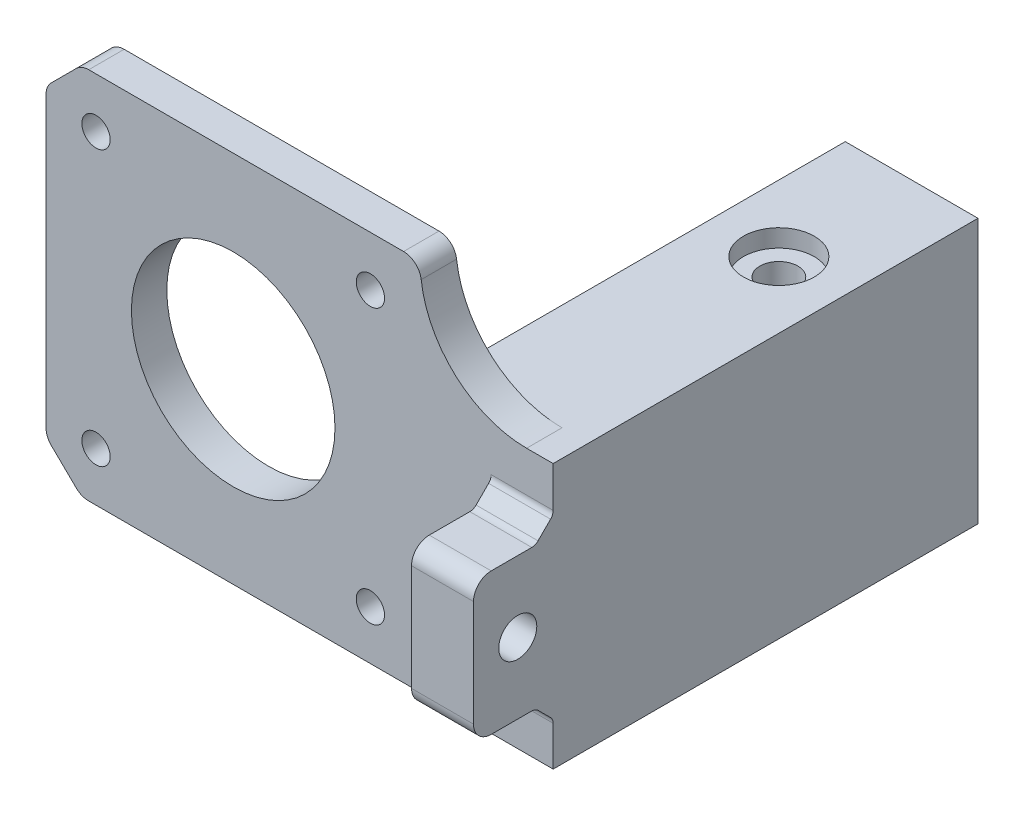
from build123d import *

# Parameters (mm, degrees)
CROQUIS1_R              = 1.6
CROQUIS1_R_2            = 11.5
SALIENTE_EXTRUIR1_DEPTH = 4
CROQUIS2_W              = 9
CROQUIS2_H              = 16
CROQUIS2_R              = 2.15
SALIENTE_EXTRUIR2_DEPTH = 7
CROQUIS3_W              = 15
CROQUIS3_H              = 42.2
SALIENTE_EXTRUIR3_DEPTH = 44
CORTAR_EXTRUIR1_START   = -12.3
CROQUIS4_W              = 15
CROQUIS4_H              = 48
CORTAR_EXTRUIR1_DEPTH   = 12.3
REDONDEO1_R             = 12
REDONDEO2_R             = 2
REDONDEO3_R             = 2
CHAFL_N1_SIZE           = 2
CHAFL_N2_SIZE           = 2
REDONDEO4_R             = 2
REDONDEO5_R             = 1
CROQUIS5_R              = 2.15
CORTAR_EXTRUIR2_DEPTH   = 30.9000001
CROQUIS5_3_R            = 4
CROQUIS5_3_R_2          = 2.15
CORTAR_EXTRUIR3_DEPTH   = 2


with BuildPart() as part:
    # Croquis1 → Saliente-Extruir1 (new body)
    with BuildSketch(Plane.XY):
        Polygon((21.15, 21.15), (17.15, 21.15), (-17.15, 21.15), (-21.15, 17.15), (-21.15, -17.15), (-17.15, -21.05), (17.15, -21.05), (36.15, -21.05), (36.15, 21.15), align=None)
        with Locations((-15.5, 15.5)):
            Circle(CROQUIS1_R, mode=Mode.SUBTRACT)
        with Locations((-15.5, -15.5)):
            Circle(CROQUIS1_R, mode=Mode.SUBTRACT)
        with Locations((15.5, 15.5)):
            Circle(CROQUIS1_R, mode=Mode.SUBTRACT)
        with Locations((15.5, -15.5)):
            Circle(CROQUIS1_R, mode=Mode.SUBTRACT)
        Circle(CROQUIS1_R_2, mode=Mode.SUBTRACT)
    extrude(amount=SALIENTE_EXTRUIR1_DEPTH)

    # Croquis2 → Saliente-Extruir2 (add)
    with BuildSketch(Plane(origin=(36.15, 0, 0), x_dir=(0, 0, -1), z_dir=(1, 0, 0))):
        with Locations((-8.5, -6.15)):
            Rectangle(CROQUIS2_W, CROQUIS2_H)
        with Locations((-8, -6.15)):
            Circle(CROQUIS2_R, mode=Mode.SUBTRACT)
    extrude(amount=-SALIENTE_EXTRUIR2_DEPTH)

    # Croquis3 → Saliente-Extruir3 (add)
    with BuildSketch(Plane(origin=(0, 0, 0), x_dir=(-1, 0, 0), z_dir=(0, 0, -1))):
        with Locations((-28.65, 0.05)):
            Rectangle(CROQUIS3_W, CROQUIS3_H)
    extrude(amount=SALIENTE_EXTRUIR3_DEPTH)

    # Croquis4 → Cortar-Extruir1 (cut)
    with BuildSketch(Plane(origin=(0, 21.15, 0), x_dir=(1, 0, 0), z_dir=(0, 1, 0)).offset(CORTAR_EXTRUIR1_START)):
        with Locations((28.65, 20)):
            Rectangle(CROQUIS4_W, CROQUIS4_H)
    extrude(amount=CORTAR_EXTRUIR1_DEPTH, mode=Mode.SUBTRACT)

    # Redondeo1
    redondeo1_edges = [part.edges().sort_by_distance(p)[0] for p in [
        (21.15, 8.85, 2),
    ]]
    fillet(redondeo1_edges, radius=REDONDEO1_R)

    # Redondeo2
    redondeo2_edges = [part.edges().sort_by_distance(p)[0] for p in [
        (21.15, 21.15, 2),
    ]]
    fillet(redondeo2_edges, radius=REDONDEO2_R)

    # Redondeo3
    redondeo3_edges = [part.edges().sort_by_distance(p)[0] for p in [
        (-17.15, -21.05, 2),
        (-21.15, -17.15, 2),
        (-21.15, 17.15, 2),
        (-17.15, 21.15, 2),
    ]]
    fillet(redondeo3_edges, radius=REDONDEO3_R)

    # Chaflán1
    chafl_n1_edges = [part.edges().sort_by_distance(p)[0] for p in [
        (32.65, 1.85, 4),
    ]]
    chamfer(chafl_n1_edges, length=CHAFL_N1_SIZE)

    # Chaflán2
    chafl_n2_edges = [part.edges().sort_by_distance(p)[0] for p in [
        (32.65, -14.15, 4),
    ]]
    chamfer(chafl_n2_edges, length=CHAFL_N2_SIZE)

    # Redondeo4
    redondeo4_edges = [part.edges().sort_by_distance(p)[0] for p in [
        (32.65, 1.85, 13),
        (32.65, -14.15, 13),
    ]]
    fillet(redondeo4_edges, radius=REDONDEO4_R)

    # Redondeo5
    redondeo5_edges = [part.edges().sort_by_distance(p)[0] for p in [
        (32.65, 3.85, 4),
        (32.65, 1.85, 6),
        (32.65, -14.15, 6),
        (32.65, -16.15, 4),
    ]]
    fillet(redondeo5_edges, radius=REDONDEO5_R)

    # Croquis5 → Cortar-Extruir2 (cut, through all)
    with BuildSketch(Plane(origin=(0, 8.85, 0), x_dir=(1, 0, 0), z_dir=(0, 1, 0))):
        with Locations((28.65, 29)):
            Circle(CROQUIS5_R)
    extrude(amount=-CORTAR_EXTRUIR2_DEPTH, mode=Mode.SUBTRACT)

    # Croquis5_3 → Cortar-Extruir3 (cut)
    with BuildSketch(Plane(origin=(0, 8.85, 0), x_dir=(1, 0, 0), z_dir=(0, 1, 0))):
        with Locations((28.65, 29)):
            Circle(CROQUIS5_3_R)
        with Locations((28.65, 29)):
            Circle(CROQUIS5_3_R_2, mode=Mode.SUBTRACT)
    extrude(amount=-CORTAR_EXTRUIR3_DEPTH, mode=Mode.SUBTRACT)


solid = part.part
